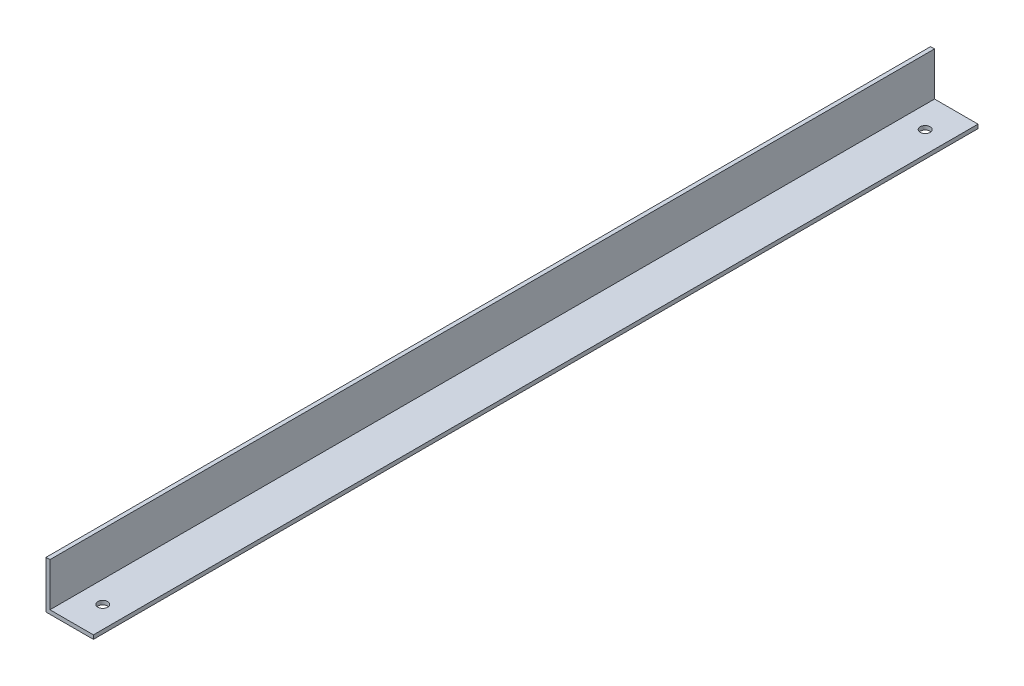
from build123d import *

# Parameters (mm, degrees)
BOSS_EXTRUDE1_DEPTH = 355.6
SKETCH3_R           = 1.984375
CUT_EXTRUDE1_DEPTH  = 1.5875


with BuildPart() as part:
    # Sketch2 → Boss-Extrude1 (new body)
    with BuildSketch(Plane.XY):
        Polygon((0, -9.525), (0, 9.525), (1.5875, 9.525), (1.5875, -7.9375), (19.05, -7.9375), (19.05, -9.525), align=None)
    extrude(amount=BOSS_EXTRUDE1_DEPTH)

    # Sketch3 → Cut-Extrude1 (cut)
    with BuildSketch(Plane(origin=(0, -7.9375, 0), x_dir=(1, 0, 0), z_dir=(0, 1, 0))):
        with Locations((10.31875, -12.5)):
            Circle(SKETCH3_R)
        with Locations((10.31875, -343.1)):
            Circle(SKETCH3_R)
    extrude(amount=-CUT_EXTRUDE1_DEPTH, mode=Mode.SUBTRACT)


solid = part.part
